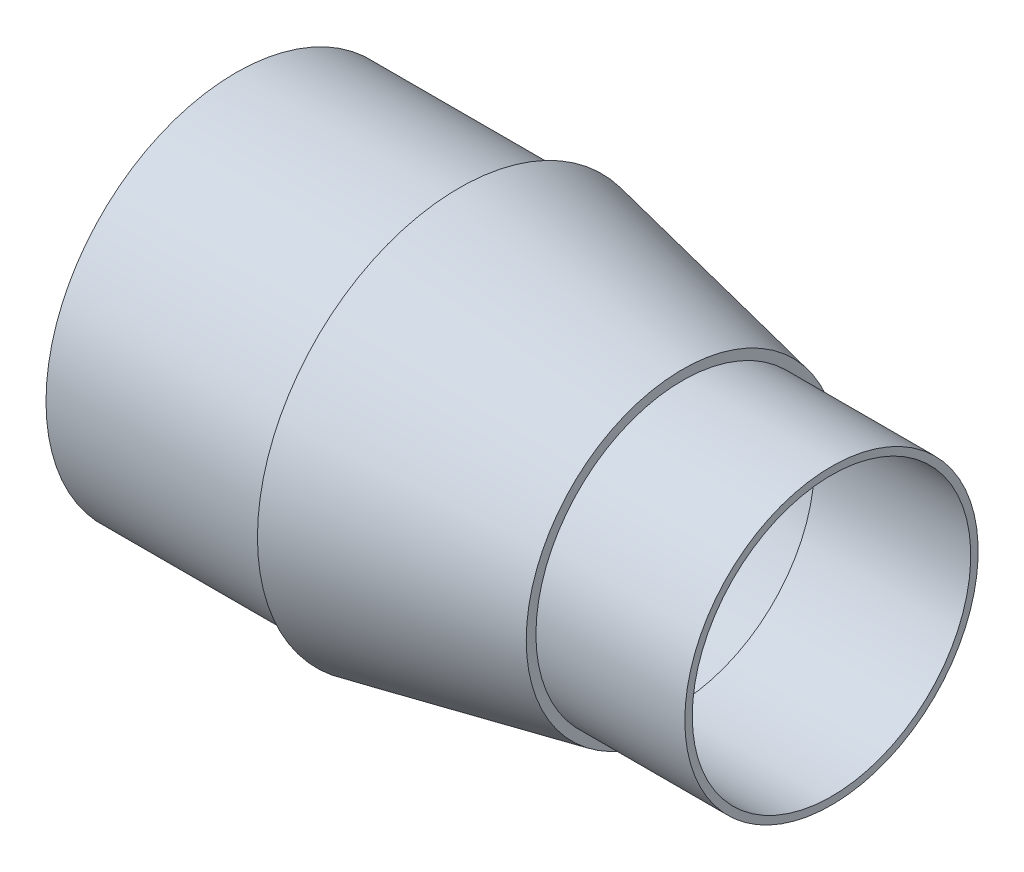
from build123d import *

# Parameters (mm, degrees)
SHELL1_T = -2.54


with BuildPart() as part:
    # Sketch1 → Revolve1 (revolve)
    with BuildSketch(Plane(origin=(0, 0, 0), x_dir=(1, 0, 0), z_dir=(0, 1, 0)), mode=Mode.PRIVATE) as revolve1_sk:
        Polygon((76.2, 68.834), (152.4, 53.34), (152.4, 50.038), (203.2, 50.038), (203.2, 0), (0, 0), (0, 64.77), (76.2, 64.77), align=None)
    revolve(revolve1_sk.sketch.rotate(Axis((0, 0, 0), (1, 0, 0)), 180), axis=Axis((0, 0, 0), (1, 0, 0)))

    # Shell1
    shell1_openings = [part.faces().sort_by_distance(p)[0] for p in [
        (0, 0, 0),
        (203.2, 0, 0),
    ]]
    offset(amount=SHELL1_T, openings=shell1_openings, kind=Kind.INTERSECTION)


solid = part.part
